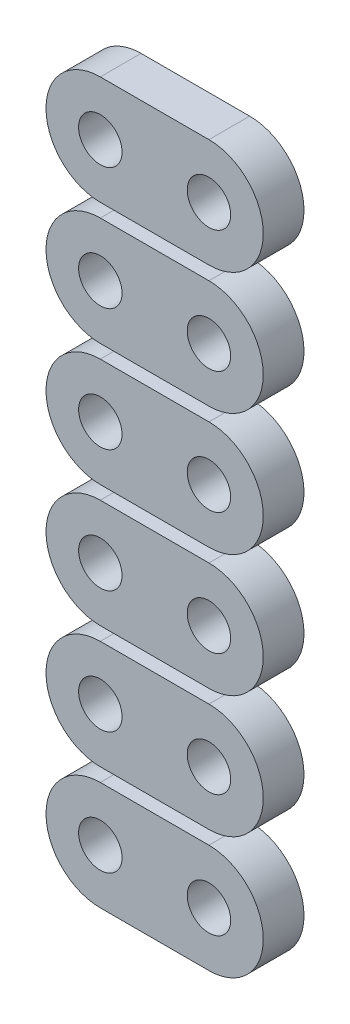
from build123d import *

# Parameters (mm, degrees)
SKETCH1_R       = 1.6
MAIN_DEPTH      = 3
LPATTERN4_COUNT = 6
LPATTERN4_PITCH = 9


with BuildPart() as part:
    # Sketch1 → Main (new body)
    with BuildSketch(Plane.XY):
        with BuildLine():
            Line((-4, 4), (4, 4))
            ThreePointArc((4, 4), (8, 0), (4, -4))
            Line((4, -4), (-4, -4))
            ThreePointArc((-4, -4), (-8, 0), (-4, 4))
        make_face()
        with Locations((-4, 0)):
            Circle(SKETCH1_R, mode=Mode.SUBTRACT)
        with Locations((4, 0)):
            Circle(SKETCH1_R, mode=Mode.SUBTRACT)
    extrude(amount=MAIN_DEPTH)


with BuildPart() as lpattern4_1:
    # LPattern4: pattern copy
    add(part.part.moved(Location(Vector(0, -1, 0) * (1 * LPATTERN4_PITCH))))


with BuildPart() as lpattern4_2:
    # LPattern4: pattern copy
    add(part.part.moved(Location(Vector(0, -1, 0) * (2 * LPATTERN4_PITCH))))


with BuildPart() as lpattern4_3:
    # LPattern4: pattern copy
    add(part.part.moved(Location(Vector(0, -1, 0) * (3 * LPATTERN4_PITCH))))


with BuildPart() as lpattern4_4:
    # LPattern4: pattern copy
    add(part.part.moved(Location(Vector(0, -1, 0) * (4 * LPATTERN4_PITCH))))


with BuildPart() as lpattern4_5:
    # LPattern4: pattern copy
    add(part.part.moved(Location(Vector(0, -1, 0) * (5 * LPATTERN4_PITCH))))


solid = Compound([part.part, lpattern4_1.part, lpattern4_2.part, lpattern4_3.part, lpattern4_4.part, lpattern4_5.part])
